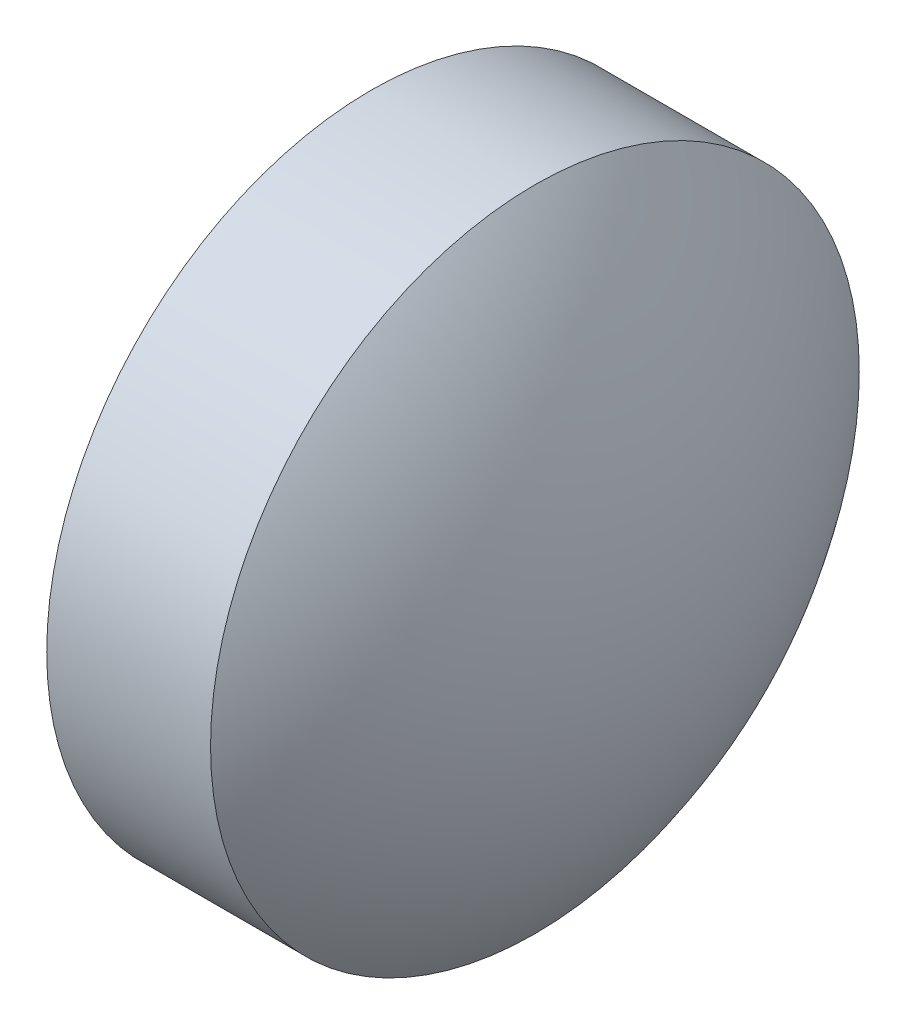
from build123d import *


with BuildPart() as part:
    # 草图1 → 旋转1 (revolve)
    with BuildSketch(Plane.XY, mode=Mode.PRIVATE) as revolve_1_sk:
        with BuildLine():
            Line((526.531233027, 150.13076894), (526.531233027, 148.13076894))
            Line((526.531233027, 148.13076894), (528.231233027, 148.13076894))
            ThreePointArc((528.231233027, 148.13076894), (528.053884563, 149.18860872), (527.541233027, 150.13076894))
            Line((527.541233027, 150.13076894), (526.531233027, 150.13076894))
        make_face()
    revolve(revolve_1_sk.sketch.rotate(Axis((525.901260588, 148.13076894, 0), (1, 0, 0)), 90), axis=Axis((525.901260588, 148.13076894, 0), (1, 0, 0)))  # turned: the seam where the file's is


solid = part.part
